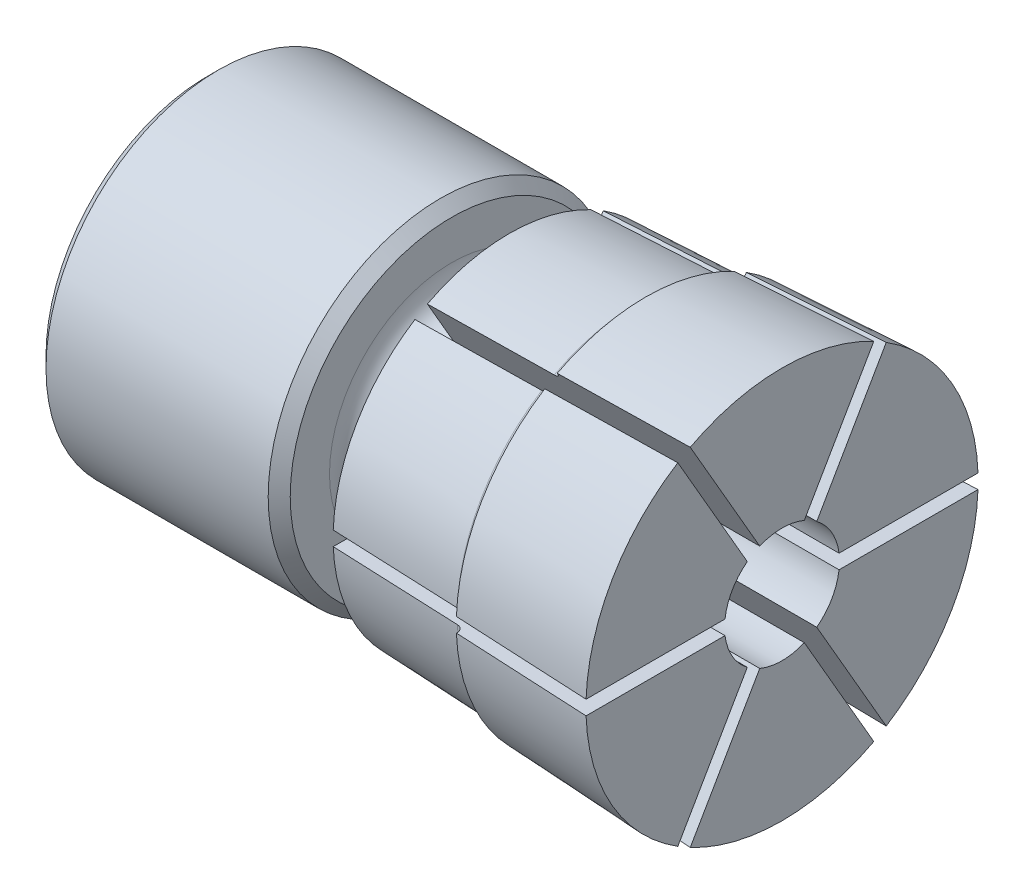
from build123d import *

# Parameters (mm, degrees)
CUT_EXTRUDE1_DEPTH = 6
CUT_EXTRUDE2_DEPTH = 40


with BuildPart() as part:
    # Sketch1 → Revolve1 (revolve)
    with BuildSketch(Plane.XY):
        with BuildLine():
            Line((8.054036255, 0), (0, 4.65))
            Line((0, 4.65), (0, 11.233))
            Line((0, 11.233), (0.767, 12))
            Line((0.767, 12), (16.233, 12))
            Line((16.233, 12), (17, 11.233))
            Line((17, 11.233), (17, 8.5))
            ThreePointArc((17, 8.5), (19, 6.5), (21, 8.5))
            Line((21, 8.5), (21, 12.25))
            Line((21, 12.25), (30.021033995, 12.62983301))
            ThreePointArc((30.021033995, 12.62983301), (30.360913423, 12.783353536), (30.5, 13.129390385))
            Line((30.5, 13.129390385), (30.5, 13.175))
            Line((30.5, 13.175), (40, 13.65))
            Line((40, 13.65), (40, 0))
            Line((40, 0), (8.054036255, 0))
        make_face()
    revolve(axis=Axis((40, 0, 0), (-1, 0, 0)))

    # Sketch2 → Cut-Extrude1 (cut)
    with BuildSketch(Plane(origin=(0, 0, 0), x_dir=(0, 0, -1), z_dir=(1, 0, 0))):
        Polygon((-4, -2.309401077), (0, -4.618802154), (4, -2.309401077), (4, 2.309401077), (0, 4.618802154), (-4, 2.309401077), align=None)
    extrude(amount=CUT_EXTRUDE1_DEPTH, mode=Mode.SUBTRACT)

    # Sketch3 → Cut-Revolve1 (revolve, cut)
    with BuildSketch(Plane(origin=(0, 0, 0), x_dir=(1, 0, 0), z_dir=(0, 1, 0))):
        Polygon((6, 0), (6, 4.75), (8, 4.75), (8, 3.5), (10, 3.5), (10, 4.2), (12, 4.2), (12, 4), (42, 4), (42, 0), align=None)
    revolve(axis=Axis((42, 0, 0), (-1, 0, 0)), mode=Mode.SUBTRACT)

    # Sketch4 → Cut-Extrude2 (cut)
    with BuildSketch(Plane(origin=(18, 0, 0), x_dir=(0, 0, -1), z_dir=(1, 0, 0))):
        Polygon((-18.65, 0.5), (-18.65, -0.5), (-0.866025404, -0.5), (-9.758012702, -15.901373781), (-8.891987298, -16.401373781), (0, -1), (8.891987298, -16.401373781), (9.758012702, -15.901373781), (0.866025404, -0.5), (18.65, -0.5), (18.65, 0.5), (0.866025404, 0.5), (9.758012702, 15.901373781), (8.891987298, 16.401373781), (0, 1), (-8.891987298, 16.401373781), (-9.758012702, 15.901373781), (-0.866025404, 0.5), align=None)
    extrude(amount=CUT_EXTRUDE2_DEPTH, mode=Mode.SUBTRACT)


solid = part.part
